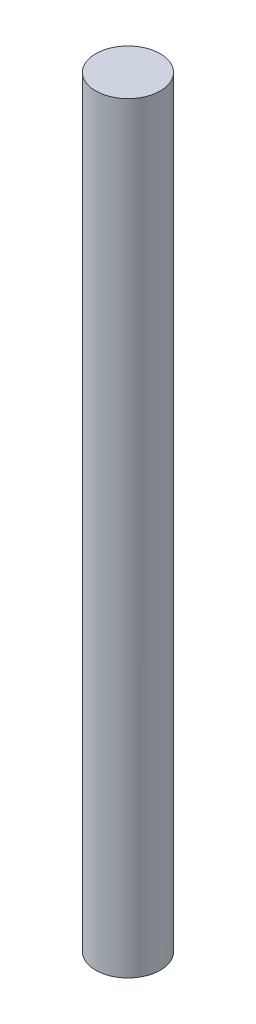
from build123d import *

# Parameters (mm, degrees)
SKETCH_1_R      = 0.75
EXTRUDE_1_DEPTH = 17.7


with BuildPart() as part:
    # 草图1 → 凸台-拉伸1 (new body)
    with BuildSketch(Plane.XZ.offset(-2.869915694)):
        Circle(SKETCH_1_R)
    extrude(amount=EXTRUDE_1_DEPTH)


solid = part.part
